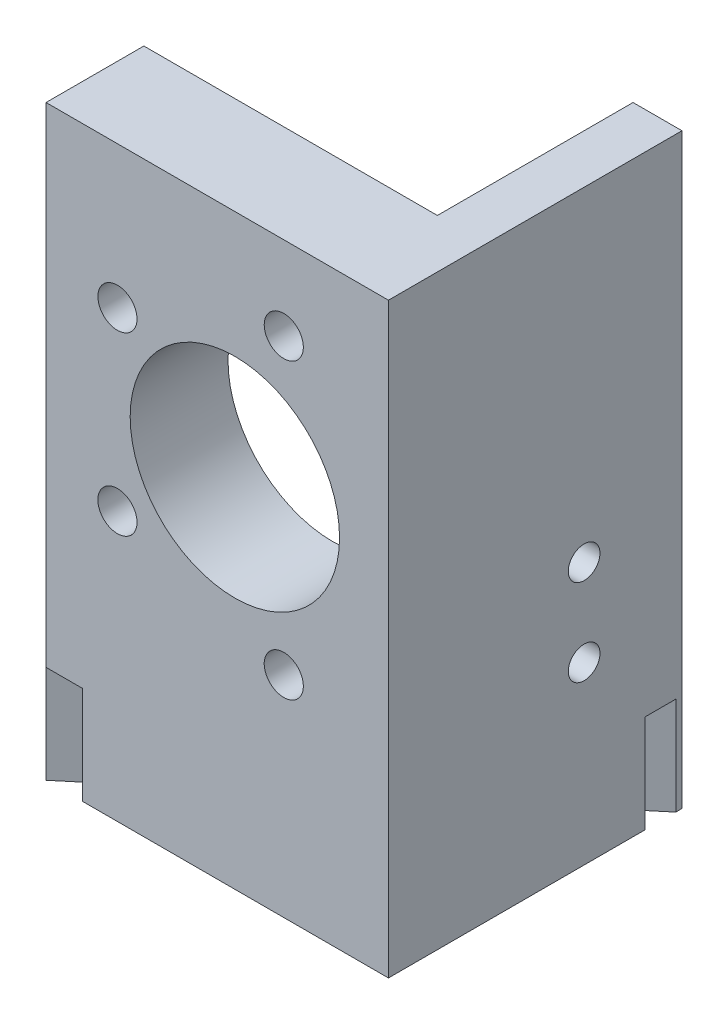
from build123d import *

# Parameters (mm, degrees)
BOSS_EXTRUDE1_DEPTH = 76.2
SKETCH4_R           = 2.0574
CUT_EXTRUDE3_DEPTH  = 7.35
SKETCH3_R           = 13.589
SKETCH3_R_2         = 2.54
CUT_EXTRUDE2_DEPTH  = 13.7
CUT_EXTRUDE4_DEPTH  = 12.7


with BuildPart() as part:
    # Sketch1 → Boss-Extrude1 (new body)
    with BuildSketch(Plane(origin=(0, 0, 0), x_dir=(1, 0, 0), z_dir=(0, 1, 0))):
        Polygon((-44.45, 12.7), (-44.45, 0), (0, 0), (0, 38.1), (-6.35, 38.1), (-6.35, 12.7), align=None)
    extrude(amount=BOSS_EXTRUDE1_DEPTH)

    # Sketch4 → Cut-Extrude3 (cut, through all)
    with BuildSketch(Plane.ZY.offset(6.35)):
        with Locations((-25.4, 22.7838)):
            Circle(SKETCH4_R)
        with Locations((-25.4, 34.036)):
            Circle(SKETCH4_R)
    extrude(amount=-CUT_EXTRUDE3_DEPTH, mode=Mode.SUBTRACT)

    # Sketch3 → Cut-Extrude2 (cut, through all)
    with BuildSketch(Plane(origin=(0, 0, -12.7), x_dir=(-1, 0, 0), z_dir=(0, 0, -1))):
        with Locations((19.939, 46.3296)):
            Circle(SKETCH3_R)
        with Locations((35.179, 57.7596)):
            Circle(SKETCH3_R_2)
        with Locations((13.589, 65.3796)):
            Circle(SKETCH3_R_2)
        with Locations((13.589, 27.2796)):
            Circle(SKETCH3_R_2)
        with Locations((35.179, 34.8996)):
            Circle(SKETCH3_R_2)
    extrude(amount=-CUT_EXTRUDE2_DEPTH, mode=Mode.SUBTRACT)

    # Sketch6 → Cut-Extrude4 (cut)
    with BuildSketch(Plane.XZ):
        Polygon((-47.891108231, 6.866314065), (10.481478335, -42.114101793), (8.522261701, -44.449005256), (-49.850324865, 4.531410602), align=None)
    extrude(amount=-CUT_EXTRUDE4_DEPTH, mode=Mode.SUBTRACT)


solid = part.part
